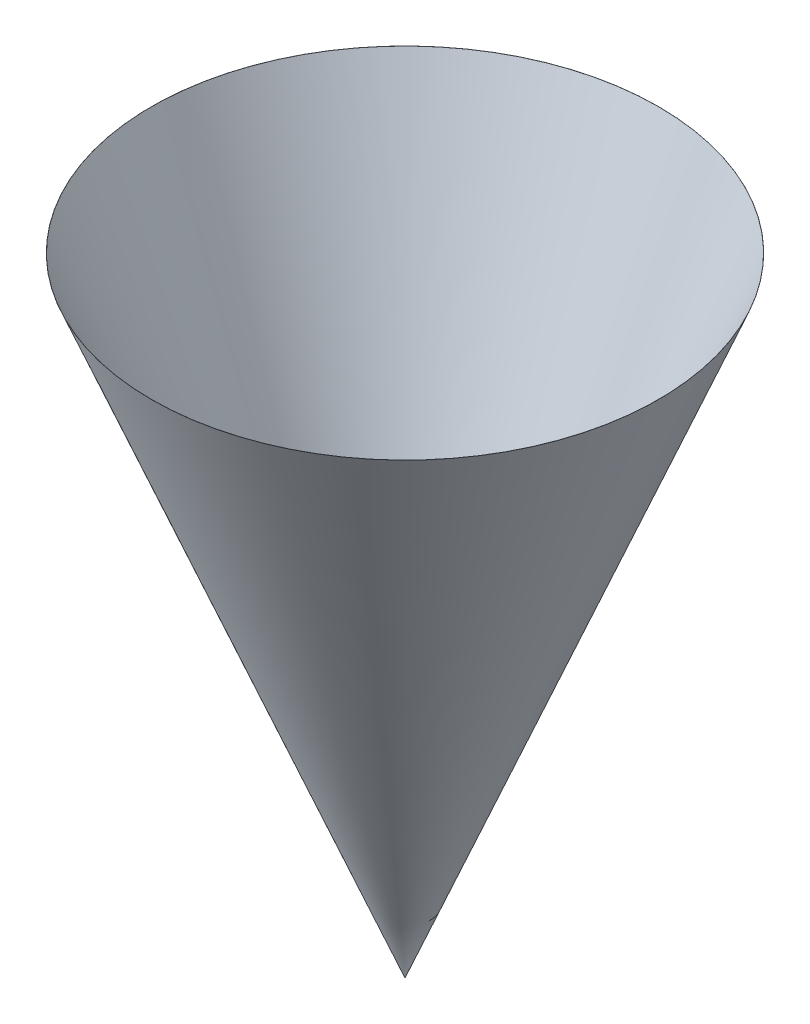
from build123d import *


with BuildPart() as part:
    # 草图2 → 旋转1 (revolve)
    with BuildSketch(Plane(origin=(0, 0, 0), x_dir=(0, 0, -1), z_dir=(1, 0, 0))):
        Polygon((0, 0), (32.322098067, 80), (32.312098067, 80), (0, 0.024750869), align=None)
    revolve(axis=Axis((0, 0, 0), (0, 1, 0)))


solid = part.part
